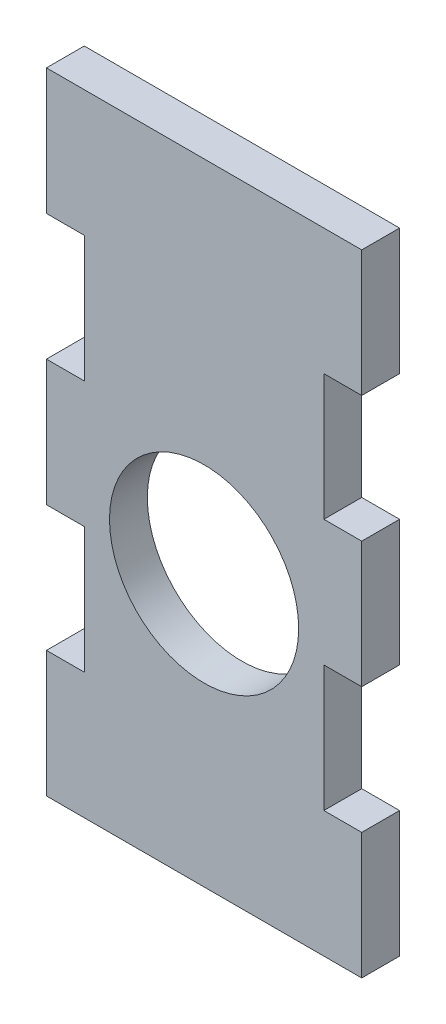
from build123d import *

# Parameters (mm, degrees)
SKETCH1_W           = 25
SKETCH1_H           = 50
BOSS_EXTRUDE1_DEPTH = 3
SKETCH2_R           = 7.5
SKETCH2_W           = 3
SKETCH2_H           = 10
CUT_EXTRUDE1_DEPTH  = 4


with BuildPart() as part:
    # Sketch1 → Boss-Extrude1 (new body)
    with BuildSketch(Plane.XY):
        Rectangle(SKETCH1_W, SKETCH1_H)
    extrude(amount=BOSS_EXTRUDE1_DEPTH)

    # Sketch2 → Cut-Extrude1 (cut, through all)
    with BuildSketch(Plane.XY.offset(3)):
        with Locations((0, -3.5)):
            Circle(SKETCH2_R)
        with Locations((11, 10)):
            Rectangle(SKETCH2_W, SKETCH2_H)
        with Locations((11, -10)):
            Rectangle(SKETCH2_W, SKETCH2_H)
        with Locations((-11, -10)):
            Rectangle(SKETCH2_W, SKETCH2_H)
        with Locations((-11, 10)):
            Rectangle(SKETCH2_W, SKETCH2_H)
    extrude(amount=-CUT_EXTRUDE1_DEPTH, mode=Mode.SUBTRACT)


solid = part.part
